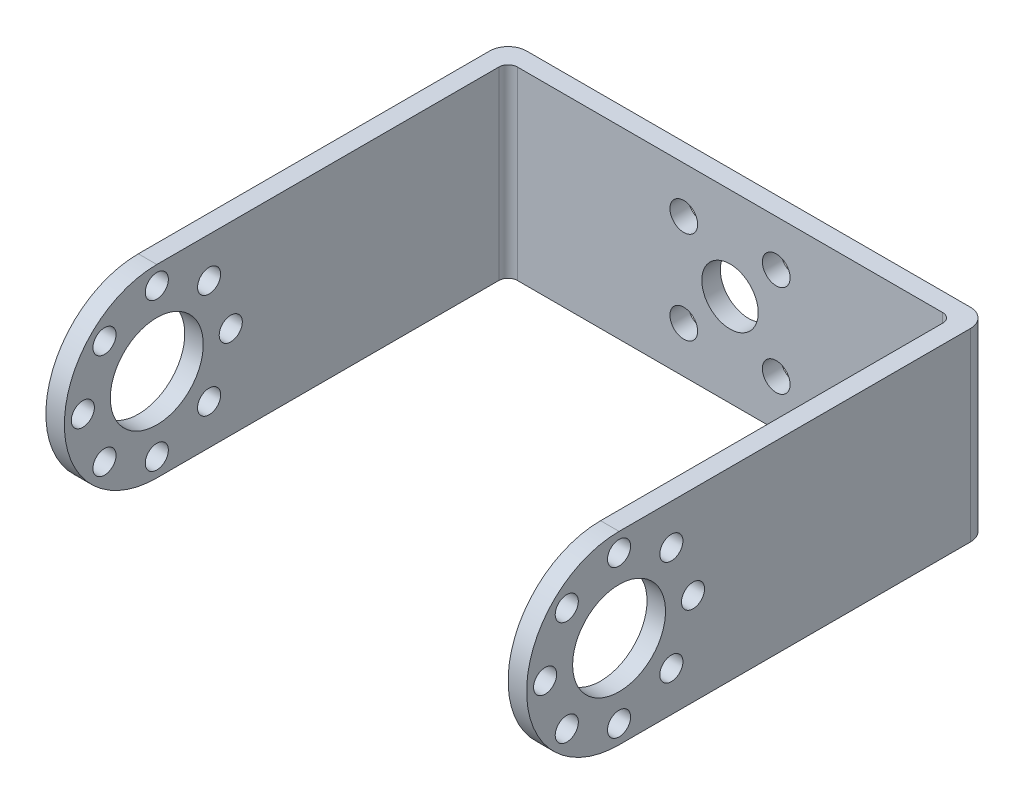
from build123d import *

# Parameters (mm, degrees)
EXTRUDE_1_DEPTH     = 20
FILLET_1_R          = 2
FILLET_2_R          = 1
CUT_EXTRUDE_1_DEPTH = 52
CUT_EXTRUDE_2_DEPTH = 52
SKETCH_4_R          = 5.025
SKETCH_4_R_2        = 1.25
CUT_EXTRUDE_3_DEPTH = 52
CUT_EXTRUDE_4_REACH = 52
SKETCH_5_R          = 3.05
SKETCH_5_R_2        = 1.5


with BuildPart() as part:
    # 草图1 → 凸台-拉伸1 (new body)
    with BuildSketch(Plane(origin=(0, 0, 0), x_dir=(1, 0, 0), z_dir=(0, 1, 0))):
        Polygon((-19.308800698, 32.095662915), (32.691199302, 32.095662915), (32.691199302, -17.904337085), (30.691199302, -17.904337085), (30.691199302, 30.095662915), (-17.308800698, 30.095662915), (-17.308800698, -17.904337085), (-19.308800698, -17.904337085), align=None)
    extrude(amount=EXTRUDE_1_DEPTH)

    # 圆角1
    fillet_1_edges = [part.edges().sort_by_distance(p)[0] for p in [
        (-19.308800698, 10, -32.095662915),
        (32.691199302, 10, -32.095662915),
    ]]
    fillet(fillet_1_edges, radius=FILLET_1_R)

    # 圆角2
    fillet_2_edges = [part.edges().sort_by_distance(p)[0] for p in [
        (30.691199302, 10, -30.095662915),
        (-17.308800698, 10, -30.095662915),
    ]]
    fillet(fillet_2_edges, radius=FILLET_2_R)

    # 草图2 → 切除-拉伸1 (cut)
    with BuildSketch(Plane.ZY.offset(19.308800698)):
        with BuildLine():
            Line((7.904337085, 20), (17.904337085, 20))
            Line((17.904337085, 20), (17.904337085, 10))
            ThreePointArc((17.904337085, 10), (14.975404897, 17.071067812), (7.904337085, 20))
        make_face()
    extrude(amount=-CUT_EXTRUDE_1_DEPTH, mode=Mode.SUBTRACT)

    # 草图3 → 切除-拉伸2 (cut)
    with BuildSketch(Plane.ZY.offset(19.308800698)):
        with BuildLine():
            Line((7.904337085, 0), (17.904337085, 0))
            Line((17.904337085, 0), (17.904337085, 10))
            ThreePointArc((17.904337085, 10), (14.975404897, 2.928932188), (7.904337085, 0))
        make_face()
    extrude(amount=-CUT_EXTRUDE_2_DEPTH, mode=Mode.SUBTRACT)

    # 草图4 → 切除-拉伸3 (cut)
    with BuildSketch(Plane.ZY.offset(19.308800698)):
        with Locations((7.904337085, 10)):
            Circle(SKETCH_4_R)
        with Locations((7.904337085, 18)):
            Circle(SKETCH_4_R_2)
        with Locations((13.561191335, 15.656854249)):
            Circle(SKETCH_4_R_2)
        with Locations((15.904337085, 10)):
            Circle(SKETCH_4_R_2)
        with Locations((13.561191335, 4.343145751)):
            Circle(SKETCH_4_R_2)
        with Locations((7.904337085, 2)):
            Circle(SKETCH_4_R_2)
        with Locations((2.247482836, 4.343145751)):
            Circle(SKETCH_4_R_2)
        with Locations((-0.095662915, 10)):
            Circle(SKETCH_4_R_2)
        with Locations((2.247482836, 15.656854249)):
            Circle(SKETCH_4_R_2)
    extrude(amount=-CUT_EXTRUDE_3_DEPTH, mode=Mode.SUBTRACT)

    # 草图5 → 切除-拉伸4 (cut, up to next)
    with BuildSketch(Plane(origin=(0, 0, -32.095662915), x_dir=(-1, 0, 0), z_dir=(0, 0, -1)), mode=Mode.PRIVATE) as cut_extrude_4_sk1:
        with Locations((-6.691199302, 10)):
            Circle(SKETCH_5_R)
    cut_extrude_4_tool1 = extrude(cut_extrude_4_sk1.sketch, amount=-CUT_EXTRUDE_4_REACH, mode=Mode.PRIVATE) & part.part
    add(cut_extrude_4_tool1.solids().sort_by_distance((6.691199, 10, -32.095663))[0], mode=Mode.SUBTRACT)
    # 草图5 → 切除-拉伸4 (cut, up to next)
    with BuildSketch(Plane(origin=(0, 0, -32.095662915), x_dir=(-1, 0, 0), z_dir=(0, 0, -1)), mode=Mode.PRIVATE) as cut_extrude_4_sk2:
        with Locations((-11.691199302, 15)):
            Circle(SKETCH_5_R_2)
    cut_extrude_4_tool2 = extrude(cut_extrude_4_sk2.sketch, amount=-CUT_EXTRUDE_4_REACH, mode=Mode.PRIVATE) & part.part
    add(cut_extrude_4_tool2.solids().sort_by_distance((11.691199, 15, -32.095663))[0], mode=Mode.SUBTRACT)
    # 草图5 → 切除-拉伸4 (cut, up to next)
    with BuildSketch(Plane(origin=(0, 0, -32.095662915), x_dir=(-1, 0, 0), z_dir=(0, 0, -1)), mode=Mode.PRIVATE) as cut_extrude_4_sk3:
        with Locations((-1.691199302, 15)):
            Circle(SKETCH_5_R_2)
    cut_extrude_4_tool3 = extrude(cut_extrude_4_sk3.sketch, amount=-CUT_EXTRUDE_4_REACH, mode=Mode.PRIVATE) & part.part
    add(cut_extrude_4_tool3.solids().sort_by_distance((1.691199, 15, -32.095663))[0], mode=Mode.SUBTRACT)
    # 草图5 → 切除-拉伸4 (cut, up to next)
    with BuildSketch(Plane(origin=(0, 0, -32.095662915), x_dir=(-1, 0, 0), z_dir=(0, 0, -1)), mode=Mode.PRIVATE) as cut_extrude_4_sk4:
        with Locations((-1.691199302, 5)):
            Circle(SKETCH_5_R_2)
    cut_extrude_4_tool4 = extrude(cut_extrude_4_sk4.sketch, amount=-CUT_EXTRUDE_4_REACH, mode=Mode.PRIVATE) & part.part
    add(cut_extrude_4_tool4.solids().sort_by_distance((1.691199, 5, -32.095663))[0], mode=Mode.SUBTRACT)
    # 草图5 → 切除-拉伸4 (cut, up to next)
    with BuildSketch(Plane(origin=(0, 0, -32.095662915), x_dir=(-1, 0, 0), z_dir=(0, 0, -1)), mode=Mode.PRIVATE) as cut_extrude_4_sk5:
        with Locations((-11.691199302, 5)):
            Circle(SKETCH_5_R_2)
    cut_extrude_4_tool5 = extrude(cut_extrude_4_sk5.sketch, amount=-CUT_EXTRUDE_4_REACH, mode=Mode.PRIVATE) & part.part
    add(cut_extrude_4_tool5.solids().sort_by_distance((11.691199, 5, -32.095663))[0], mode=Mode.SUBTRACT)


solid = part.part
